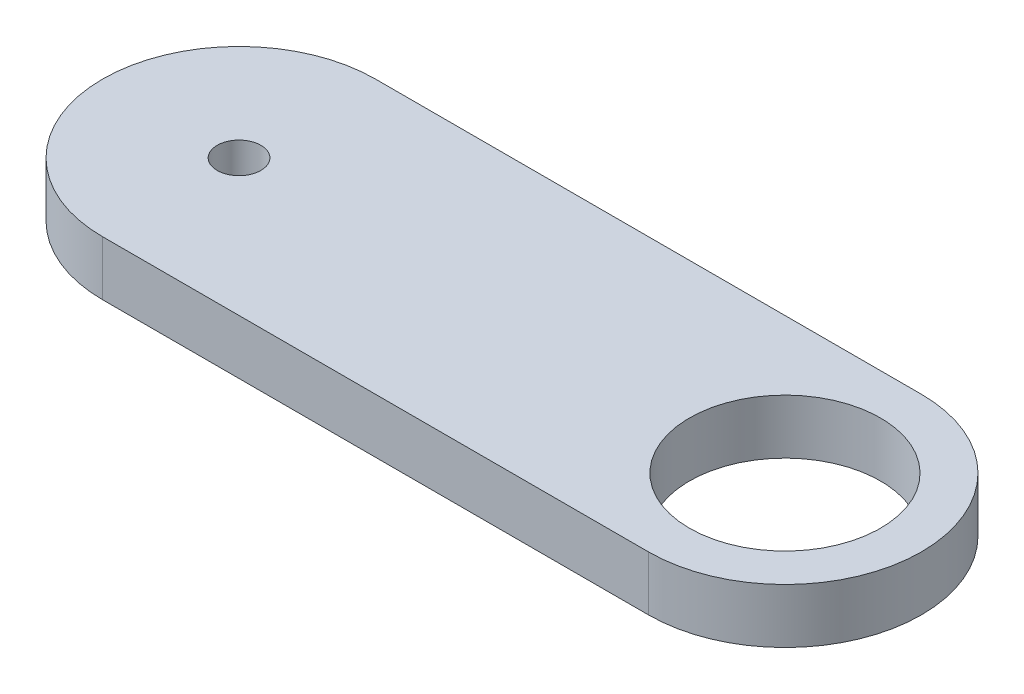
from build123d import *

# Parameters (mm, degrees)
SKETCH1_R           = 4
SKETCH1_R_2         = 17.5
BOSS_EXTRUDE1_DEPTH = 10


with BuildPart() as part:
    # Sketch1 → Boss-Extrude1 (new body)
    with BuildSketch(Plane(origin=(0, 0, 0), x_dir=(1, 0, 0), z_dir=(0, 1, 0))):
        with BuildLine():
            Line((0, 25), (100, 25))
            ThreePointArc((100, 25), (125, 0), (100, -25))
            Line((100, -25), (0, -25))
            ThreePointArc((0, -25), (-25, 0), (0, 25))
        make_face()
        Circle(SKETCH1_R, mode=Mode.SUBTRACT)
        with Locations((100, 0)):
            Circle(SKETCH1_R_2, mode=Mode.SUBTRACT)
    extrude(amount=BOSS_EXTRUDE1_DEPTH)


solid = part.part
